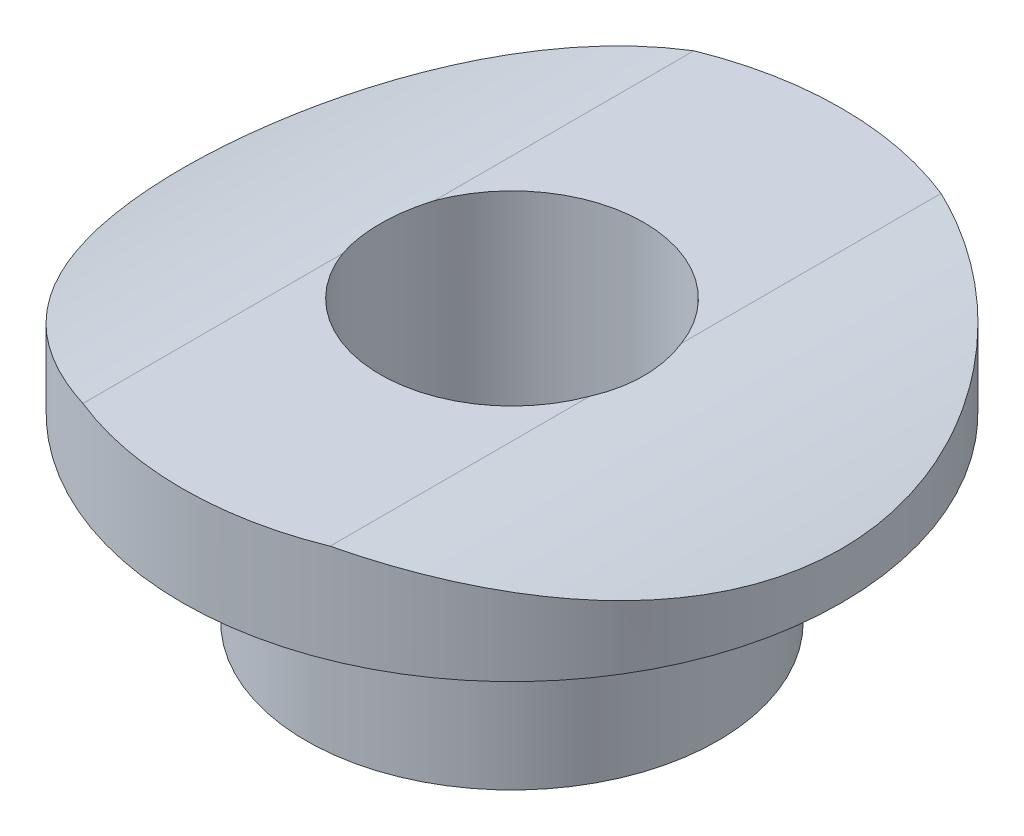
from build123d import *

# Parameters (mm, degrees)
SKETCH3_R               = 19.05
SKETCH3_R_2             = 14.351
CUT_EXTRUDE1_DEPTH      = 6.08
CUT_EXTRUDE1_DEPTH_BACK = 6.08


with BuildPart() as part:
    # Sketch1 → Revolve1 (revolve)
    with BuildSketch(Plane.XY):
        Polygon((-2.032, 0), (-3.175, 0), (-3.175, 2.794), (-5.08, 2.794), (-5.08, 4.318), (-2.032, 4.318), align=None)
    revolve(axis=Axis((0, 0, 0), (0, 1, 0)))

    # Sketch3 → Cut-Extrude1 (cut, two sides)
    with BuildSketch(Plane.XY) as cut_extrude1_sk:
        with Locations((0, -9.906)):
            Circle(SKETCH3_R)
        with Locations((0, -9.906)):
            Circle(SKETCH3_R_2, mode=Mode.SUBTRACT)
    extrude(amount=CUT_EXTRUDE1_DEPTH, mode=Mode.SUBTRACT)
    extrude(cut_extrude1_sk.sketch, amount=-CUT_EXTRUDE1_DEPTH_BACK, mode=Mode.SUBTRACT)


solid = part.part
